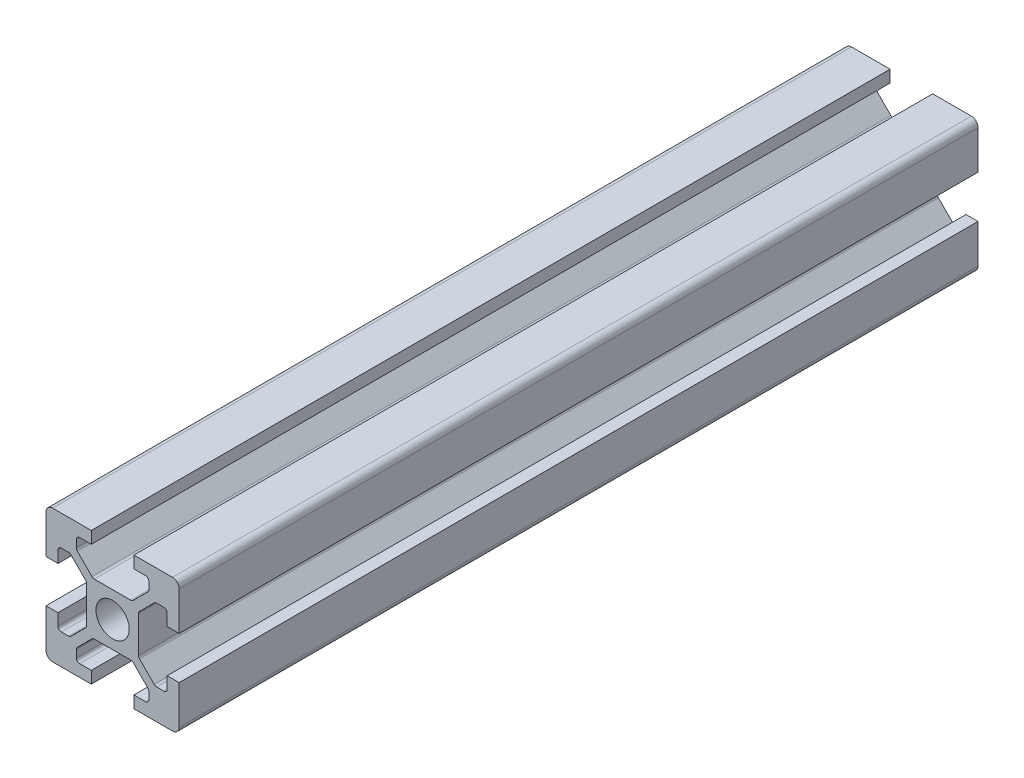
from build123d import *

# Parameters (mm, degrees)
SKETCH1_R           = 2.5
BOSS_EXTRUDE1_DEPTH = 300
SKETCH2_W           = 20
SKETCH2_H           = 180
CUT_EXTRUDE1_DEPTH  = 30


with BuildPart() as part:
    # Sketch1 → Boss-Extrude1 (new body)
    with BuildSketch(Plane(origin=(0, 0, 0), x_dir=(-1, 0, 0), z_dir=(0, 0, -1))):
        with BuildLine():
            Line((-20, 19), (-20, 13.2))
            Line((-20, 13.2), (-18.2, 13.2))
            Line((-18.2, 13.2), (-18.2, 14.95))
            ThreePointArc((-18.2, 14.95), (-18.053553391, 15.303553391), (-17.7, 15.45))
            Line((-17.7, 15.45), (-16.607106781, 15.45))
            ThreePointArc((-16.607106781, 15.45), (-16.415765065, 15.411939766), (-16.253553391, 15.303553391))
            Line((-16.253553391, 15.303553391), (-14.046446609, 13.096446609))
            ThreePointArc((-14.046446609, 13.096446609), (-13.938060234, 12.934234935), (-13.9, 12.742893219))
            Line((-13.9, 12.742893219), (-13.9, 7.257106781))
            ThreePointArc((-13.9, 7.257106781), (-13.938060234, 7.065765065), (-14.046446609, 6.903553391))
            Line((-14.046446609, 6.903553391), (-16.253553391, 4.696446609))
            ThreePointArc((-16.253553391, 4.696446609), (-16.415765065, 4.588060234), (-16.607106781, 4.55))
            Line((-16.607106781, 4.55), (-17.7, 4.55))
            ThreePointArc((-17.7, 4.55), (-18.053553391, 4.696446609), (-18.2, 5.05))
            Line((-18.2, 5.05), (-18.2, 6.8))
            Line((-18.2, 6.8), (-20, 6.8))
            Line((-20, 6.8), (-20, 1))
            ThreePointArc((-20, 1), (-19.707106781, 0.292893219), (-19, 0))
            Line((-19, 0), (-13.2, 0))
            Line((-13.2, 0), (-13.2, 1.8))
            Line((-13.2, 1.8), (-14.95, 1.8))
            ThreePointArc((-14.95, 1.8), (-15.303553391, 1.946446609), (-15.45, 2.3))
            Line((-15.45, 2.3), (-15.45, 3.392893219))
            ThreePointArc((-15.45, 3.392893219), (-15.411939766, 3.584234935), (-15.303553391, 3.746446609))
            Line((-15.303553391, 3.746446609), (-13.096446609, 5.953553391))
            ThreePointArc((-13.096446609, 5.953553391), (-12.934234935, 6.061939766), (-12.742893219, 6.1))
            Line((-12.742893219, 6.1), (-7.257106781, 6.1))
            ThreePointArc((-7.257106781, 6.1), (-7.065765065, 6.061939766), (-6.903553391, 5.953553391))
            Line((-6.903553391, 5.953553391), (-4.696446609, 3.746446609))
            ThreePointArc((-4.696446609, 3.746446609), (-4.588060234, 3.584234935), (-4.55, 3.392893219))
            Line((-4.55, 3.392893219), (-4.55, 2.3))
            ThreePointArc((-4.55, 2.3), (-4.696446609, 1.946446609), (-5.05, 1.8))
            Line((-5.05, 1.8), (-6.8, 1.8))
            Line((-6.8, 1.8), (-6.8, 0))
            Line((-6.8, 0), (-1, 0))
            ThreePointArc((-1, 0), (-0.292893219, 0.292893219), (0, 1))
            Line((0, 1), (0, 6.8))
            Line((0, 6.8), (-1.8, 6.8))
            Line((-1.8, 6.8), (-1.8, 5.05))
            ThreePointArc((-1.8, 5.05), (-1.946446609, 4.696446609), (-2.3, 4.55))
            Line((-2.3, 4.55), (-3.392893219, 4.55))
            ThreePointArc((-3.392893219, 4.55), (-3.584234935, 4.588060234), (-3.746446609, 4.696446609))
            Line((-3.746446609, 4.696446609), (-5.953553391, 6.903553391))
            ThreePointArc((-5.953553391, 6.903553391), (-6.061939766, 7.065765065), (-6.1, 7.257106781))
            Line((-6.1, 7.257106781), (-6.1, 12.742893219))
            ThreePointArc((-6.1, 12.742893219), (-6.061939766, 12.934234935), (-5.953553391, 13.096446609))
            Line((-5.953553391, 13.096446609), (-3.746446609, 15.303553391))
            ThreePointArc((-3.746446609, 15.303553391), (-3.584234935, 15.411939766), (-3.392893219, 15.45))
            Line((-3.392893219, 15.45), (-2.3, 15.45))
            ThreePointArc((-2.3, 15.45), (-1.946446609, 15.303553391), (-1.8, 14.95))
            Line((-1.8, 14.95), (-1.8, 13.2))
            Line((-1.8, 13.2), (0, 13.2))
            Line((0, 13.2), (0, 19))
            ThreePointArc((0, 19), (-0.292893219, 19.707106781), (-1, 20))
            Line((-1, 20), (-6.8, 20))
            Line((-6.8, 20), (-6.8, 18.2))
            Line((-6.8, 18.2), (-5.05, 18.2))
            ThreePointArc((-5.05, 18.2), (-4.696446609, 18.053553391), (-4.55, 17.7))
            Line((-4.55, 17.7), (-4.55, 16.607106781))
            ThreePointArc((-4.55, 16.607106781), (-4.588060234, 16.415765065), (-4.696446609, 16.253553391))
            Line((-4.696446609, 16.253553391), (-6.903553391, 14.046446609))
            ThreePointArc((-6.903553391, 14.046446609), (-7.065765065, 13.938060234), (-7.257106781, 13.9))
            Line((-7.257106781, 13.9), (-12.742893219, 13.9))
            ThreePointArc((-12.742893219, 13.9), (-12.934234935, 13.938060234), (-13.096446609, 14.046446609))
            Line((-13.096446609, 14.046446609), (-15.303553391, 16.253553391))
            ThreePointArc((-15.303553391, 16.253553391), (-15.411939766, 16.415765065), (-15.45, 16.607106781))
            Line((-15.45, 16.607106781), (-15.45, 17.7))
            ThreePointArc((-15.45, 17.7), (-15.303553391, 18.053553391), (-14.95, 18.2))
            Line((-14.95, 18.2), (-13.2, 18.2))
            Line((-13.2, 18.2), (-13.2, 20))
            Line((-13.2, 20), (-19, 20))
            ThreePointArc((-19, 20), (-19.707106781, 19.707106781), (-20, 19))
        make_face()
        with Locations((-10, 10)):
            Circle(SKETCH1_R, mode=Mode.SUBTRACT)
    extrude(amount=-BOSS_EXTRUDE1_DEPTH)

    # Sketch2 → Cut-Extrude1 (cut)
    with BuildSketch(Plane(origin=(0, 20, 0), x_dir=(1, 0, 0), z_dir=(0, 1, 0))):
        with Locations((10, -90)):
            Rectangle(SKETCH2_W, SKETCH2_H)
    extrude(amount=-CUT_EXTRUDE1_DEPTH, mode=Mode.SUBTRACT)


solid = part.part
